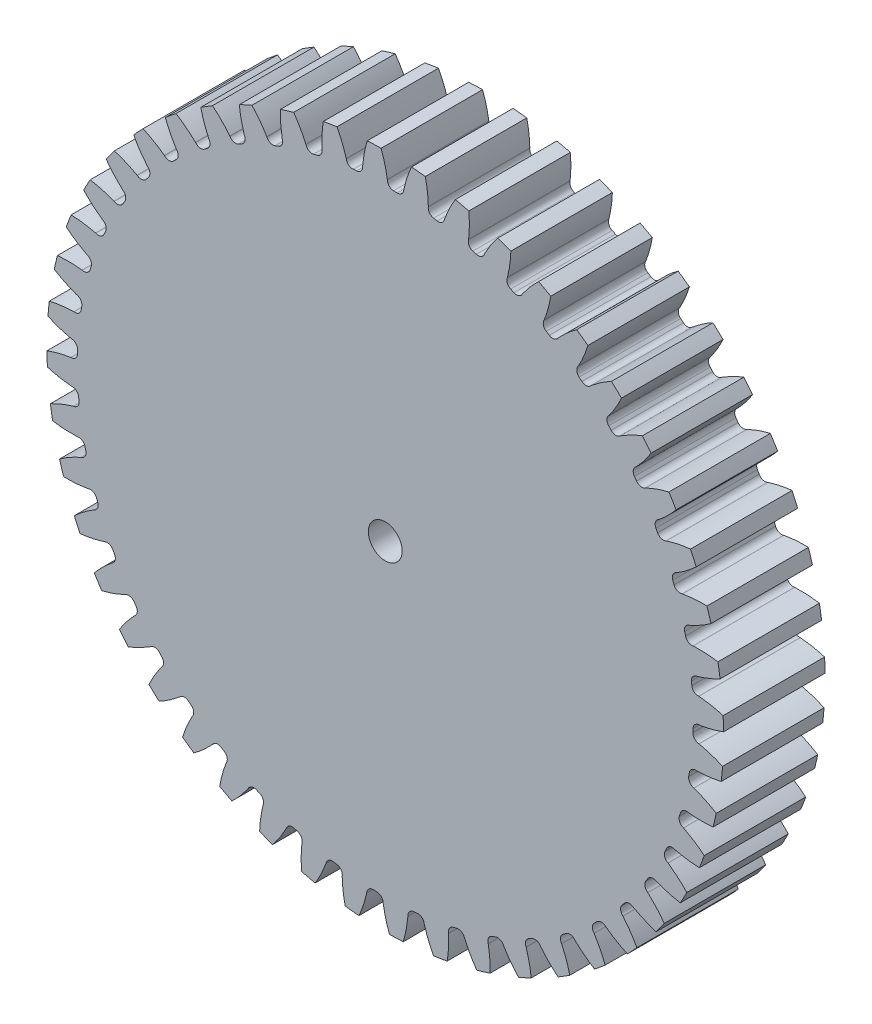
from build123d import *

# Parameters (mm, degrees)
SKETCH1_R                = 31.75
BOSS_EXTRUDE1_DEPTH      = 9.525
CUT_EXTRUDE1_DEPTH       = 10.525
FILLET1_R                = 0.5984748
CIRPATTERN1_COUNT        = 48
FILLET1_OF_CIRPATTERN1_R = 0.5984748
SKETCH5_R                = 1.5875
CUT_EXTRUDE2_DEPTH       = 10.5250007


with BuildPart() as part:
    # Sketch1 → Boss-Extrude1 (new body)
    with BuildSketch(Plane.XY):
        Circle(SKETCH1_R)
    extrude(amount=-BOSS_EXTRUDE1_DEPTH)

    # Sketch4 → Cut-Extrude1 (cut, through all)
    with BuildSketch(Plane.XY):
        with BuildLine():
            Line((0.192007592, 29.508515403), (0.192007592, 28.891861991))
            ThreePointArc((0.192007592, 28.891861991), (0.94533831, 28.877030521), (1.698026109, 28.842559935))
            Line((1.698026109, 28.842559935), (1.738357266, 29.457893037))
            add(Edge.make_bspline(
                [(5.347443251, 35.57703422), (2.509323071, 32.949977288), (1.738357266, 29.457893037)],
                knots=[0, 0, 0, 1, 1, 1], degree=2))
            ThreePointArc((5.347443251, 35.57703422), (1.177126274, 35.957403785), (-3.00913911, 35.850601041))
            add(Edge.make_bspline(
                [(-3.00913911, 35.850601041), (-0.348913737, 33.043546492), (0.192007592, 29.508515403)],
                knots=[0, 0, 0, 1, 1, 1], degree=2))
        make_face()
    cut_extrude1 = extrude(amount=-CUT_EXTRUDE1_DEPTH, mode=Mode.SUBTRACT)

    # Fillet1
    fillet1_edges = [part.edges().sort_by_distance(p)[0] for p in [
        (1.698026109, 28.842559935, -4.7625),
        (0.192007592, 28.891861991, -4.7625),
    ]]
    fillet(fillet1_edges, radius=FILLET1_R)

    # CirPattern1: Cut-Extrude1 ×48 about axis
    cirpattern1_axis = Axis((0, 0, -9.525), (0, 0, 1))
    for i in range(1, CIRPATTERN1_COUNT):
        add(cut_extrude1.rotate(cirpattern1_axis, i * 360 / CIRPATTERN1_COUNT), mode=Mode.SUBTRACT)

    # Fillet1 of CirPattern1
    fillet1_of_cirpattern1_edges = [part.edges().sort_by_distance(p)[0] for p in [
        (-2.081210262, 28.817444718, -4.7625),
        (-3.580779792, 28.669750127, -4.7625),
        (-5.824836548, 28.299255033, -4.7625),
        (-7.29229904, 27.957090889, -4.7625),
        (-9.468798266, 27.296857249, -4.7625),
        (-10.87904503, 26.766078074, -4.7625),
        (-12.95074622, 25.827402668, -4.7625),
        (-14.279647544, 25.117090243, -4.7625),
        (-16.211103316, 23.916034067, -4.7625),
        (-17.435921329, 23.038342034, -4.7625),
        (-19.19408394, 21.595455493, -4.7625),
        (-20.293861665, 20.565401405, -4.7625),
        (-21.848648466, 18.905372688, -4.7625),
        (-22.804568402, 17.740581057, -4.7625),
        (-24.129376559, 15.891813714, -4.7625),
        (-24.925082651, 14.612214448, -4.7625),
        (-25.997244329, 12.606341402, -4.7625),
        (-26.619121826, 11.233828798, -4.7625),
        (-27.420292041, 9.105171093, -4.7625),
        (-27.857700446, 7.663229223, -4.7625),
        (-28.374170954, 5.448208783, -4.7625),
        (-28.619626087, 3.961509672, -4.7625),
        (-28.842559935, 1.698026109, -4.7625),
        (-28.891861991, 0.192007592, -4.7625),
        (-28.817444718, -2.081210262, -4.7625),
        (-28.669750127, -3.580779792, -4.7625),
        (-28.299255033, -5.824836548, -4.7625),
        (-27.957090889, -7.29229904, -4.7625),
        (-27.296857249, -9.468798266, -4.7625),
        (-26.766078074, -10.87904503, -4.7625),
        (-25.827402668, -12.95074622, -4.7625),
        (-25.117090243, -14.279647544, -4.7625),
        (-23.916034067, -16.211103316, -4.7625),
        (-23.038342034, -17.435921329, -4.7625),
        (-21.595455493, -19.19408394, -4.7625),
        (-20.565401405, -20.293861665, -4.7625),
        (-18.905372688, -21.848648466, -4.7625),
        (-17.740581057, -22.804568402, -4.7625),
        (-15.891813714, -24.129376559, -4.7625),
        (-14.612214448, -24.925082651, -4.7625),
        (-12.606341402, -25.997244329, -4.7625),
        (-11.233828798, -26.619121826, -4.7625),
        (-9.105171093, -27.420292041, -4.7625),
        (-7.663229223, -27.857700446, -4.7625),
        (-5.448208783, -28.374170954, -4.7625),
        (-3.961509672, -28.619626087, -4.7625),
        (-1.698026109, -28.842559935, -4.7625),
        (-0.192007592, -28.891861991, -4.7625),
        (2.081210262, -28.817444718, -4.7625),
        (3.580779792, -28.669750127, -4.7625),
        (5.824836548, -28.299255033, -4.7625),
        (7.29229904, -27.957090889, -4.7625),
        (9.468798266, -27.296857249, -4.7625),
        (10.87904503, -26.766078074, -4.7625),
        (12.95074622, -25.827402668, -4.7625),
        (14.279647544, -25.117090243, -4.7625),
        (16.211103316, -23.916034067, -4.7625),
        (17.435921329, -23.038342034, -4.7625),
        (19.19408394, -21.595455493, -4.7625),
        (20.293861665, -20.565401405, -4.7625),
        (21.848648466, -18.905372688, -4.7625),
        (22.804568402, -17.740581057, -4.7625),
        (24.129376559, -15.891813714, -4.7625),
        (24.925082651, -14.612214448, -4.7625),
        (25.997244329, -12.606341402, -4.7625),
        (26.619121826, -11.233828798, -4.7625),
        (27.420292041, -9.105171093, -4.7625),
        (27.857700446, -7.663229223, -4.7625),
        (28.374170954, -5.448208783, -4.7625),
        (28.619626087, -3.961509672, -4.7625),
        (28.842559935, -1.698026109, -4.7625),
        (28.891861991, -0.192007592, -4.7625),
        (28.817444718, 2.081210262, -4.7625),
        (28.669750127, 3.580779792, -4.7625),
        (28.299255033, 5.824836548, -4.7625),
        (27.957090889, 7.29229904, -4.7625),
        (27.296857249, 9.468798266, -4.7625),
        (26.766078074, 10.87904503, -4.7625),
        (25.827402668, 12.95074622, -4.7625),
        (25.117090243, 14.279647544, -4.7625),
        (23.916034067, 16.211103316, -4.7625),
        (23.038342034, 17.435921329, -4.7625),
        (21.595455493, 19.19408394, -4.7625),
        (20.565401405, 20.293861665, -4.7625),
        (18.905372688, 21.848648466, -4.7625),
        (17.740581057, 22.804568402, -4.7625),
        (15.891813714, 24.129376559, -4.7625),
        (14.612214448, 24.925082651, -4.7625),
        (12.606341402, 25.997244329, -4.7625),
        (11.233828798, 26.619121826, -4.7625),
        (9.105171093, 27.420292041, -4.7625),
        (7.663229223, 27.857700446, -4.7625),
        (5.448208783, 28.374170954, -4.7625),
        (3.961509672, 28.619626087, -4.7625),
    ]]
    fillet(fillet1_of_cirpattern1_edges, radius=FILLET1_OF_CIRPATTERN1_R)

    # Sketch5 → Cut-Extrude2 (cut, through all)
    with BuildSketch(Plane.XY):
        Circle(SKETCH5_R)
    extrude(amount=-CUT_EXTRUDE2_DEPTH, mode=Mode.SUBTRACT)


solid = part.part
